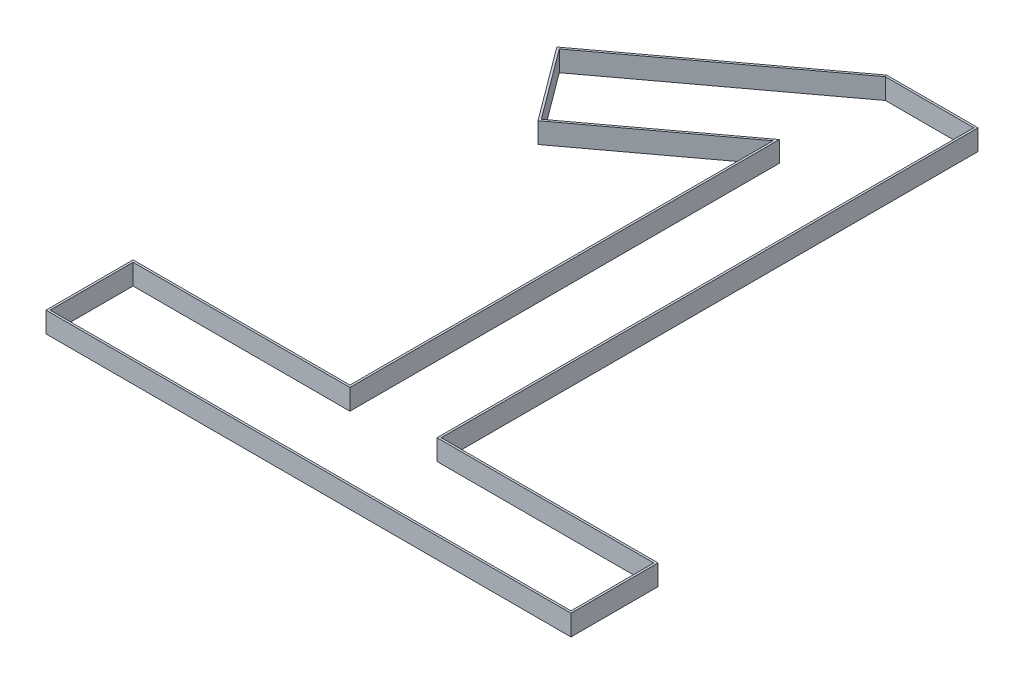
from build123d import *

# Parameters (mm, degrees)
BOSS_EXTRUDE1_DEPTH = 1


with BuildPart() as part:
    # Sketch1 → Boss-Extrude1 (new body)
    with BuildSketch(Plane(origin=(0, 0, 0), x_dir=(1, 0, 0), z_dir=(0, 1, 0))):
        Polygon((-12.726436998, 0), (12.726436998, 0), (12.726436998, 4.221634294), (2.211948406, 4.221634294), (2.211948406, 30.250890115), (-2.211948406, 30.250890115), (-11.390670326, 23.432410974), (-8.752594478, 19.881155024), (-2.211948406, 24.739920677), (-2.211948406, 4.221634294), (-12.726436998, 4.221634294), align=None)
        Polygon((-2.178869719, 30.150890115), (-11.250763541, 23.411768989), (-8.731952493, 20.021061809), (-2.111948406, 24.938779131), (-2.111948406, 4.121634294), (-12.626436998, 4.121634294), (-12.626436998, 0.1), (12.626436998, 0.1), (12.626436998, 4.121634294), (2.111948406, 4.121634294), (2.111948406, 30.150890115), align=None, mode=Mode.SUBTRACT)
    extrude(amount=BOSS_EXTRUDE1_DEPTH)


solid = part.part
